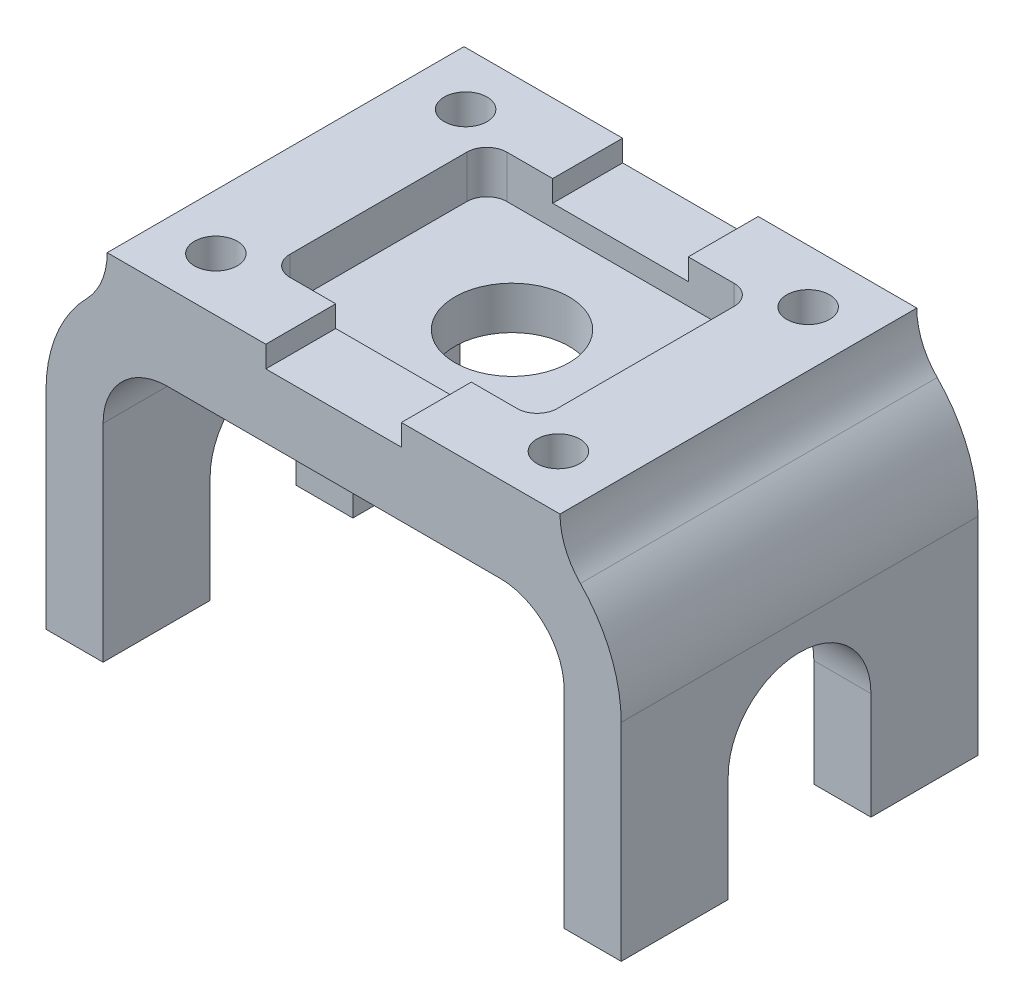
from build123d import *

# Parameters (mm, degrees)
BOSS_EXTRUDE1_DEPTH = 31.75
CUT_EXTRUDE1_DEPTH  = 103.362
CUT_EXTRUDE2_DEPTH  = 7.62
SKETCH5_W           = 24.13
SKETCH5_H           = 3.81
CUT_EXTRUDE3_DEPTH  = 64.5
CUT_EXTRUDE4_REACH  = 57.88
SKETCH6_R           = 10.16
CUT_EXTRUDE5_REACH  = 65.5
SKETCH7_R           = 3.81


with BuildPart() as part:
    # Sketch2 → Boss-Extrude1 (new body, symmetric)
    with BuildSketch(Plane.XY):
        with BuildLine():
            Line((-29.591, 0), (29.591, 0))
            ThreePointArc((29.591, 0), (37.673230509, -3.347769491), (41.021, -11.43))
            Line((41.021, -11.43), (41.021, -48.26))
            Line((41.021, -48.26), (51.181, -48.26))
            Line((51.181, -48.26), (51.181, -11.43))
            ThreePointArc((51.181, -11.43), (49.29585059, -1.827302371), (43.920228208, 6.35))
            ThreePointArc((43.920228208, 6.35), (41.232417018, 10.438651186), (40.289842313, 15.24))
            Line((40.289842313, 15.24), (-40.289842313, 15.24))
            ThreePointArc((-40.289842313, 15.24), (-41.232417018, 10.438651186), (-43.920228208, 6.35))
            ThreePointArc((-43.920228208, 6.35), (-49.29585059, -1.827302371), (-51.181, -11.43))
            Line((-51.181, -11.43), (-51.181, -48.26))
            Line((-51.181, -48.26), (-41.021, -48.26))
            Line((-41.021, -48.26), (-41.021, -11.43))
            ThreePointArc((-41.021, -11.43), (-37.673230509, -3.347769491), (-29.591, 0))
        make_face()
    extrude(amount=BOSS_EXTRUDE1_DEPTH, both=True)

    # Sketch3 → Cut-Extrude1 (cut, through all)
    with BuildSketch(Plane(origin=(51.181, 0, 0), x_dir=(0, 0, -1), z_dir=(1, 0, 0))):
        with BuildLine():
            Line((-12.7, -48.26), (12.7, -48.26))
            Line((12.7, -48.26), (12.7, -29.21))
            ThreePointArc((12.7, -29.21), (0, -16.51), (-12.7, -29.21))
            Line((-12.7, -29.21), (-12.7, -48.26))
        make_face()
    extrude(amount=-CUT_EXTRUDE1_DEPTH, mode=Mode.SUBTRACT)

    # Sketch4 → Cut-Extrude2 (cut)
    with BuildSketch(Plane(origin=(0, 15.24, 0), x_dir=(1, 0, 0), z_dir=(0, 1, 0))):
        with BuildLine():
            Line((-20.223842313, 19.304), (20.223842313, 19.304))
            ThreePointArc((20.223842313, 19.304), (22.738314027, 18.262471714), (23.779842313, 15.748))
            Line((23.779842313, 15.748), (23.779842313, -15.748))
            ThreePointArc((23.779842313, -15.748), (22.738314027, -18.262471714), (20.223842313, -19.304))
            Line((20.223842313, -19.304), (-20.223842313, -19.304))
            ThreePointArc((-20.223842313, -19.304), (-22.738314027, -18.262471714), (-23.779842313, -15.748))
            Line((-23.779842313, -15.748), (-23.779842313, 15.748))
            ThreePointArc((-23.779842313, 15.748), (-22.738314027, 18.262471714), (-20.223842313, 19.304))
        make_face()
    extrude(amount=-CUT_EXTRUDE2_DEPTH, mode=Mode.SUBTRACT)

    # Sketch5 → Cut-Extrude3 (cut, through all)
    with BuildSketch(Plane.XY.offset(31.75)):
        with Locations((0, 13.335)):
            Rectangle(SKETCH5_W, SKETCH5_H)
    extrude(amount=-CUT_EXTRUDE3_DEPTH, mode=Mode.SUBTRACT)

    # Sketch6 → Cut-Extrude4 (cut, up to next)
    with BuildSketch(Plane(origin=(0, 7.62, 0), x_dir=(1, 0, 0), z_dir=(0, 1, 0)), mode=Mode.PRIVATE) as cut_extrude4_sk1:
        Circle(SKETCH6_R)
    cut_extrude4_tool1 = extrude(cut_extrude4_sk1.sketch, amount=-CUT_EXTRUDE4_REACH, mode=Mode.PRIVATE) & part.part
    add(cut_extrude4_tool1.solids().sort_by_distance((0, 7.62, 0))[0], mode=Mode.SUBTRACT)

    # Sketch7 → Cut-Extrude5 (cut, up to next)
    with BuildSketch(Plane(origin=(0, 15.24, 0), x_dir=(1, 0, 0), z_dir=(0, 1, 0)), mode=Mode.PRIVATE) as cut_extrude5_sk1:
        with Locations((-30.48, 22.225)):
            Circle(SKETCH7_R)
    cut_extrude5_tool1 = extrude(cut_extrude5_sk1.sketch, amount=-CUT_EXTRUDE5_REACH, mode=Mode.PRIVATE) & part.part
    add(cut_extrude5_tool1.solids().sort_by_distance((-30.48, 15.24, -22.225))[0], mode=Mode.SUBTRACT)
    # Sketch7 → Cut-Extrude5 (cut, up to next)
    with BuildSketch(Plane(origin=(0, 15.24, 0), x_dir=(1, 0, 0), z_dir=(0, 1, 0)), mode=Mode.PRIVATE) as cut_extrude5_sk2:
        with Locations((30.48, 22.225)):
            Circle(SKETCH7_R)
    cut_extrude5_tool2 = extrude(cut_extrude5_sk2.sketch, amount=-CUT_EXTRUDE5_REACH, mode=Mode.PRIVATE) & part.part
    add(cut_extrude5_tool2.solids().sort_by_distance((30.48, 15.24, -22.225))[0], mode=Mode.SUBTRACT)
    # Sketch7 → Cut-Extrude5 (cut, up to next)
    with BuildSketch(Plane(origin=(0, 15.24, 0), x_dir=(1, 0, 0), z_dir=(0, 1, 0)), mode=Mode.PRIVATE) as cut_extrude5_sk3:
        with Locations((30.48, -22.225)):
            Circle(SKETCH7_R)
    cut_extrude5_tool3 = extrude(cut_extrude5_sk3.sketch, amount=-CUT_EXTRUDE5_REACH, mode=Mode.PRIVATE) & part.part
    add(cut_extrude5_tool3.solids().sort_by_distance((30.48, 15.24, 22.225))[0], mode=Mode.SUBTRACT)
    # Sketch7 → Cut-Extrude5 (cut, up to next)
    with BuildSketch(Plane(origin=(0, 15.24, 0), x_dir=(1, 0, 0), z_dir=(0, 1, 0)), mode=Mode.PRIVATE) as cut_extrude5_sk4:
        with Locations((-30.48, -22.225)):
            Circle(SKETCH7_R)
    cut_extrude5_tool4 = extrude(cut_extrude5_sk4.sketch, amount=-CUT_EXTRUDE5_REACH, mode=Mode.PRIVATE) & part.part
    add(cut_extrude5_tool4.solids().sort_by_distance((-30.48, 15.24, 22.225))[0], mode=Mode.SUBTRACT)


solid = part.part
